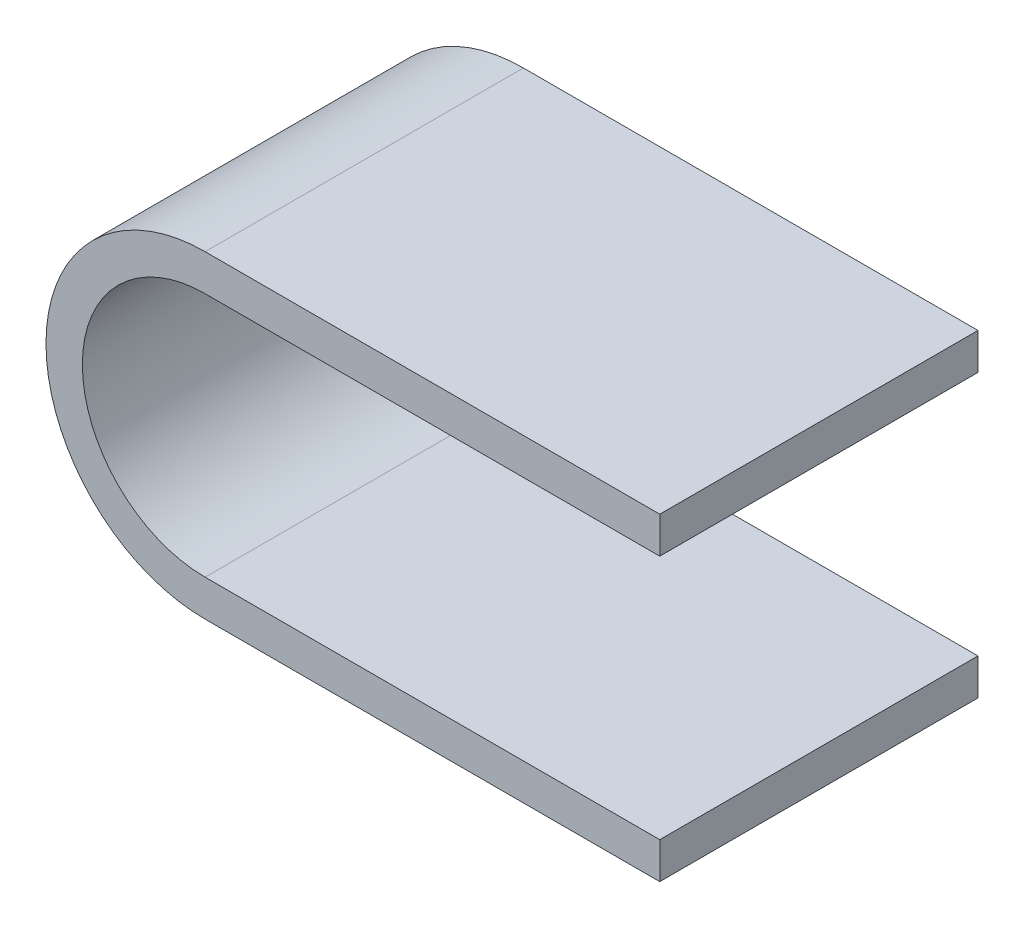
from build123d import *

# Parameters (mm, degrees)
BOSS_EXTRU_1_DEPTH = 35


with BuildPart() as part:
    # Esquisse2 → Boss.-Extru.1 (new body)
    with BuildSketch(Plane.XY):
        with BuildLine():
            Line((0, 0), (-50, 0))
            ThreePointArc((-50, 0), (-67.5, 17.5), (-50, 35))
            Line((-50, 35), (0, 35))
            Line((0, 35), (0, 31))
            Line((0, 31), (-50, 31))
            ThreePointArc((-50, 31), (-63.5, 17.5), (-50, 4))
            Line((-50, 4), (0, 4))
            Line((0, 4), (0, 0))
        make_face()
    extrude(amount=BOSS_EXTRU_1_DEPTH)


solid = part.part
